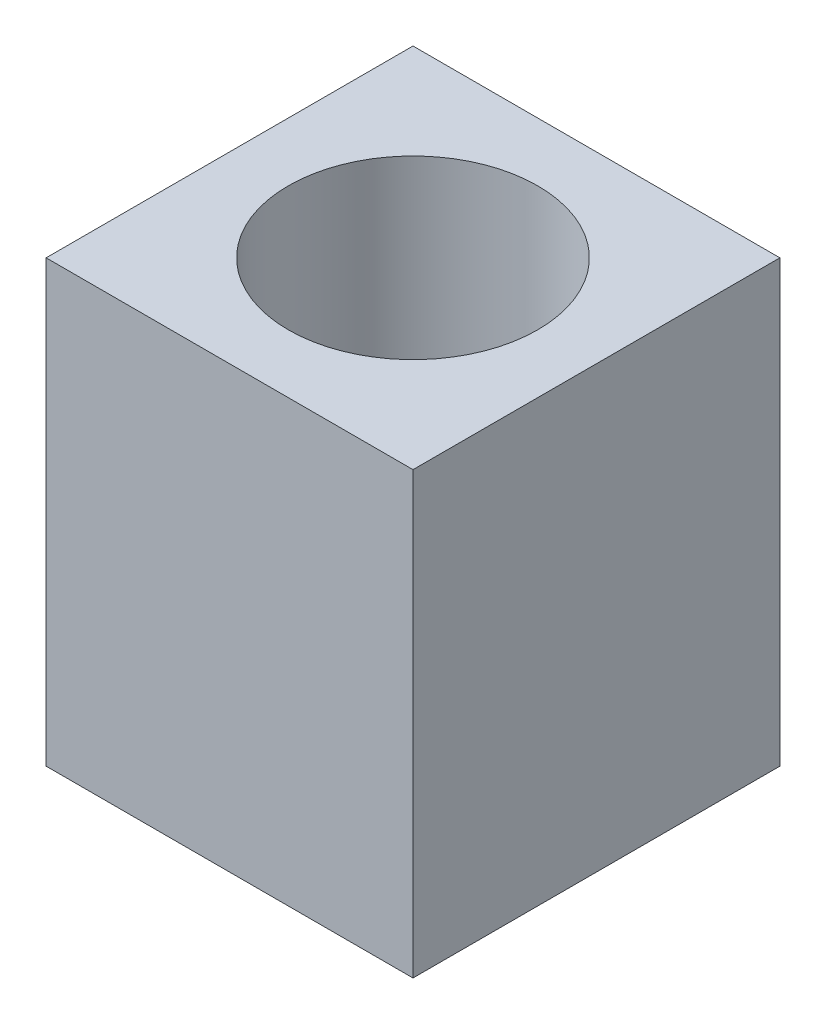
from build123d import *

# Parameters (mm, degrees)
SKETCH1_W           = 5
SKETCH1_H           = 5
SKETCH1_R           = 1.7
BOSS_EXTRUDE1_DEPTH = 6


with BuildPart() as part:
    # Sketch1 → Boss-Extrude1 (new body)
    with BuildSketch(Plane(origin=(0, 0, 0), x_dir=(1, 0, 0), z_dir=(0, 1, 0))):
        Rectangle(SKETCH1_W, SKETCH1_H)
        Circle(SKETCH1_R, mode=Mode.SUBTRACT)
    extrude(amount=BOSS_EXTRUDE1_DEPTH)


solid = part.part
